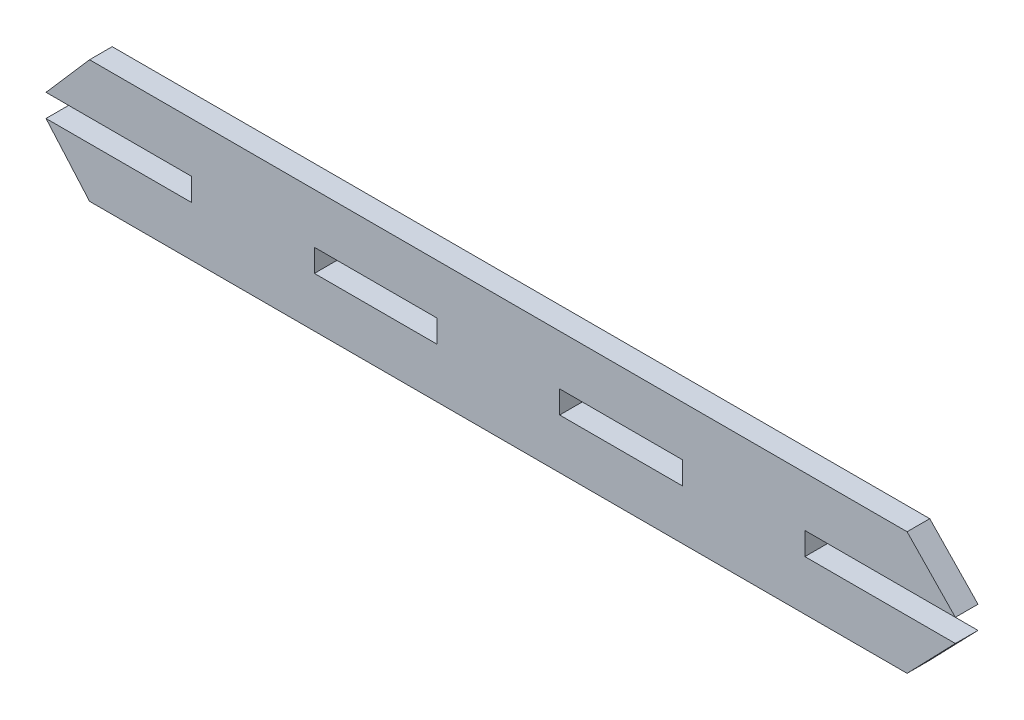
from build123d import *

# Parameters (mm, degrees)
SKETCH2_W           = 30
SKETCH2_H           = 5.54
BOSS_EXTRUDE1_DEPTH = 5.54


with BuildPart() as part:
    # Sketch2 → Boss-Extrude1 (new body)
    with BuildSketch(Plane.XY):
        Polygon((70.883682838, 21.365273538), (270.883682838, 21.365273538), (282.687189303, 9.135273538), (245.883682838, 9.135273538), (245.883682838, 3.595273538), (282.687189303, 3.595273538), (270.883682838, -8.634726462), (70.883682838, -8.634726462), (60.2283454, 3.595273538), (95.883682838, 3.595273538), (95.883682838, 9.135273538), (60.2283454, 9.135273538), align=None)
        with Locations((200.883682838, 6.365273538)):
            Rectangle(SKETCH2_W, SKETCH2_H, mode=Mode.SUBTRACT)
        with Locations((140.883682838, 6.365273538)):
            Rectangle(SKETCH2_W, SKETCH2_H, mode=Mode.SUBTRACT)
    extrude(amount=BOSS_EXTRUDE1_DEPTH)


solid = part.part
